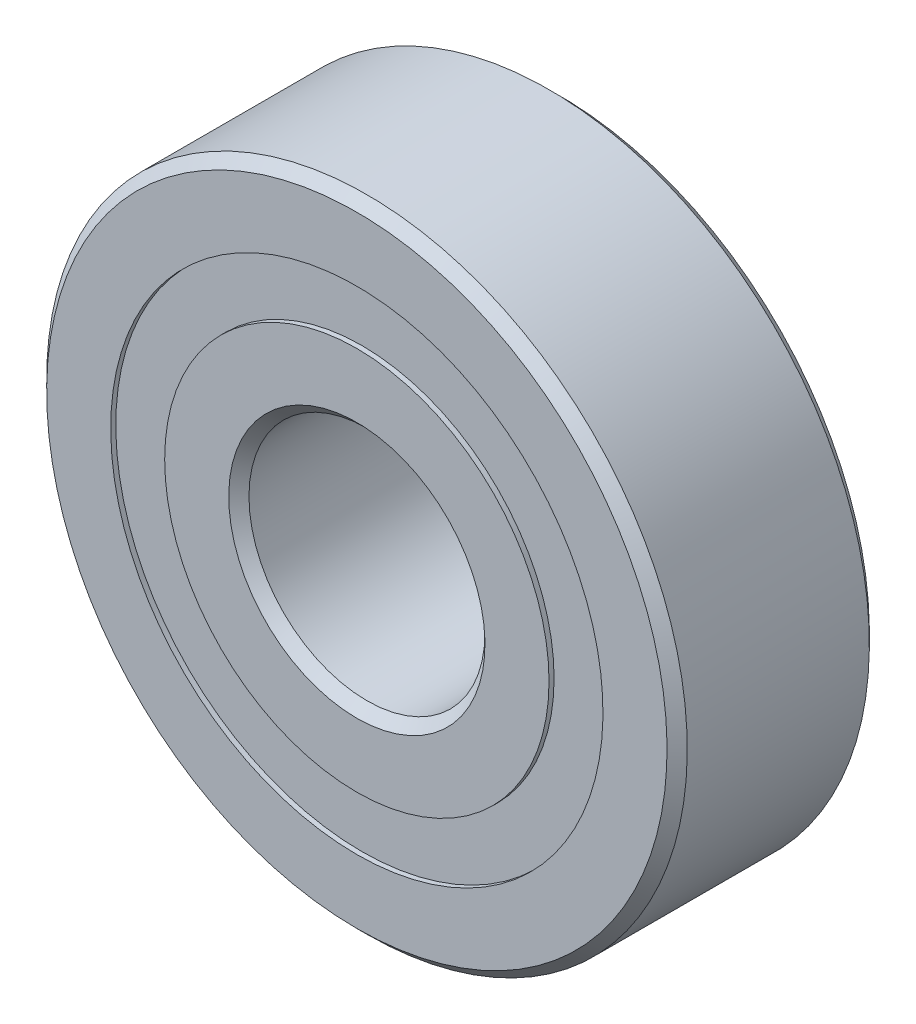
from build123d import *

# Parameters (mm, degrees)
CIRPATTERN1_COUNT = 6
SKETCH5_W         = 1.295079495
SKETCH5_H         = 1.6


with BuildPart() as part:
    # Sketch7 → Revolve6 (revolve)
    with BuildSketch(Plane(origin=(0, 0, 0), x_dir=(0, 0, -1), z_dir=(1, 0, 0))):
        with BuildLine():
            Line((2.7, 9.5), (3, 9.2))
            Line((3, 9.2), (3, 7.3))
            Line((3, 7.3), (1.333333333, 7.3))
            ThreePointArc((1.333333333, 7.3), (0, 8.054920505), (-1.333333333, 7.3))
            Line((-1.333333333, 7.3), (-3, 7.3))
            Line((-3, 7.3), (-3, 9.2))
            Line((-3, 9.2), (-2.7, 9.5))
            Line((-2.7, 9.5), (2.7, 9.5))
        make_face()
    revolve(axis=Axis((0, 0, 3), (0, 0, -1)))


with BuildPart() as body_2:
    # Sketch3 → Revolve3 (revolve)
    with BuildSketch(Plane(origin=(0, 0, 0), x_dir=(0, 0, -1), z_dir=(1, 0, 0))):
        with BuildLine():
            Line((-2.7, 3.5), (-3, 3.8))
            Line((-3, 3.8), (-3, 5.7))
            Line((-3, 5.7), (-1.333333333, 5.7))
            ThreePointArc((-1.333333333, 5.7), (0, 4.945079495), (1.333333333, 5.7))
            Line((1.333333333, 5.7), (3, 5.7))
            Line((3, 5.7), (3, 3.8))
            Line((3, 3.8), (2.7, 3.5))
            Line((2.7, 3.5), (-2.7, 3.5))
        make_face()
    revolve(axis=Axis((0, 0, 3), (0, 0, -1)))


with BuildPart() as body_3:
    # Sketch4 → Revolve4 (revolve)
    with BuildSketch(Plane(origin=(0, 0, 0), x_dir=(0, 0, -1), z_dir=(1, 0, 0))):
        with BuildLine():
            Line((-1.554920505, 6.5), (1.554920505, 6.5))
            ThreePointArc((1.554920505, 6.5), (0, 8.054920505), (-1.554920505, 6.5))
        make_face()
    revolve(axis=Axis((0, 6.5, 1.554920505), (0, 0, -1)))


with BuildPart() as cirpattern1_1:
    # CirPattern1: pattern copy
    add(body_3.part.rotate(Axis((0, 0, 0), (0, 0, 1)), 1 * 360 / CIRPATTERN1_COUNT))


with BuildPart() as cirpattern1_2:
    # CirPattern1: pattern copy
    add(body_3.part.rotate(Axis((0, 0, 0), (0, 0, 1)), 2 * 360 / CIRPATTERN1_COUNT))


with BuildPart() as cirpattern1_3:
    # CirPattern1: pattern copy
    add(body_3.part.rotate(Axis((0, 0, 0), (0, 0, 1)), 3 * 360 / CIRPATTERN1_COUNT))


with BuildPart() as cirpattern1_4:
    # CirPattern1: pattern copy
    add(body_3.part.rotate(Axis((0, 0, 0), (0, 0, 1)), 4 * 360 / CIRPATTERN1_COUNT))


with BuildPart() as cirpattern1_5:
    # CirPattern1: pattern copy
    add(body_3.part.rotate(Axis((0, 0, 0), (0, 0, 1)), 5 * 360 / CIRPATTERN1_COUNT))


with BuildPart() as body_9:
    # Sketch5 → Revolve5 (revolve)
    with BuildSketch(Plane(origin=(0, 0, 0), x_dir=(0, 0, -1), z_dir=(1, 0, 0))):
        with Locations((-2.202460252, 6.5)):
            Rectangle(SKETCH5_W, SKETCH5_H)
        with Locations((2.202460252, 6.5)):
            Rectangle(SKETCH5_W, SKETCH5_H)
    revolve(axis=Axis((0, 0, 3), (0, 0, -1)))


solid = Compound([part.part, body_2.part, body_3.part, cirpattern1_1.part, cirpattern1_2.part, cirpattern1_3.part, cirpattern1_4.part, cirpattern1_5.part, body_9.part])
